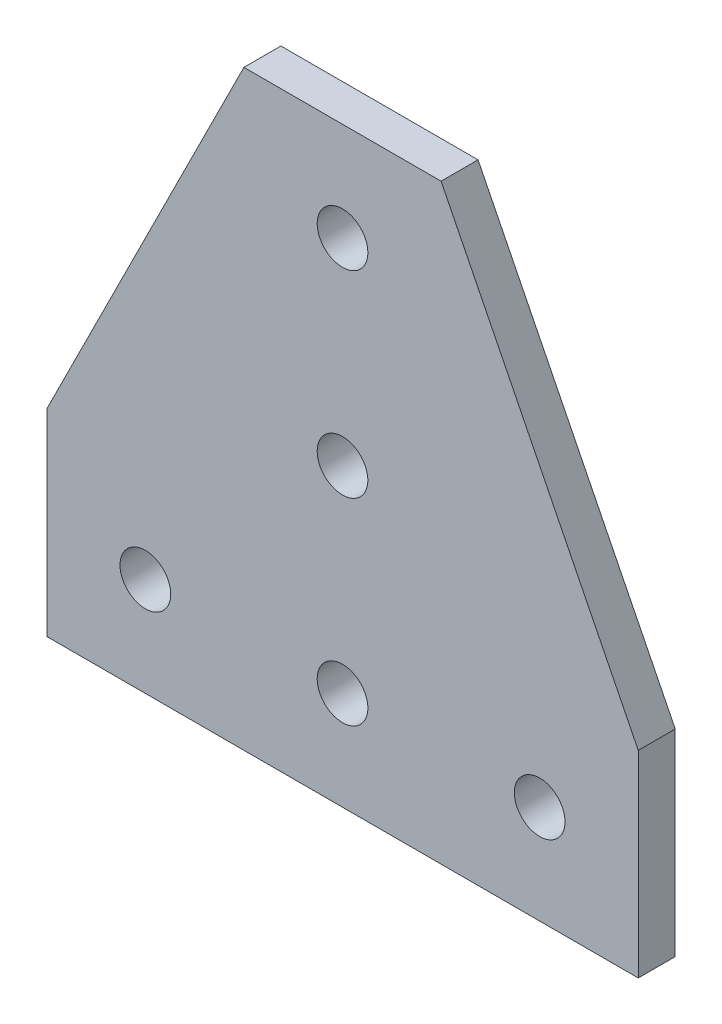
from build123d import *

# Parameters (mm, degrees)
EXTRUDE1_DEPTH   = 4.7625
SKETCH3_R        = 3.2639
SINGLE_TEE_DEPTH = 5.7625


with BuildPart() as part:
    # Sketch1 → Extrude1 (new body)
    with BuildSketch(Plane.XY):
        Polygon((12.7, 25.4), (25.4, 25.4), (25.4, -50.8), (-12.7, -50.8), (-12.7, -25.4), align=None)
    extrude(amount=-EXTRUDE1_DEPTH)

    # Mirror1: part across plane


with BuildPart() as part_1:
    add(part.part)
    add(part.part.mirror(Plane(origin=(25.4, 25.4, -4.7625), x_dir=(0, 0, 1), z_dir=(1, 0, 0))))

    # Sketch3 → single tee (cut, through all)
    with BuildSketch(Plane(origin=(0, 0, -4.7625), x_dir=(-1, 0, 0), z_dir=(0, 0, -1))):
        with Locations((-25.4, -38.1)):
            Circle(SKETCH3_R)
        with Locations((-25.4, -12.7)):
            Circle(SKETCH3_R)
        with Locations((-25.4, 12.7)):
            Circle(SKETCH3_R)
        with Locations((-50.8, -38.1)):
            Circle(SKETCH3_R)
        with Locations((0, -38.1)):
            Circle(SKETCH3_R)
    extrude(amount=-SINGLE_TEE_DEPTH, mode=Mode.SUBTRACT)


solid = part_1.part
